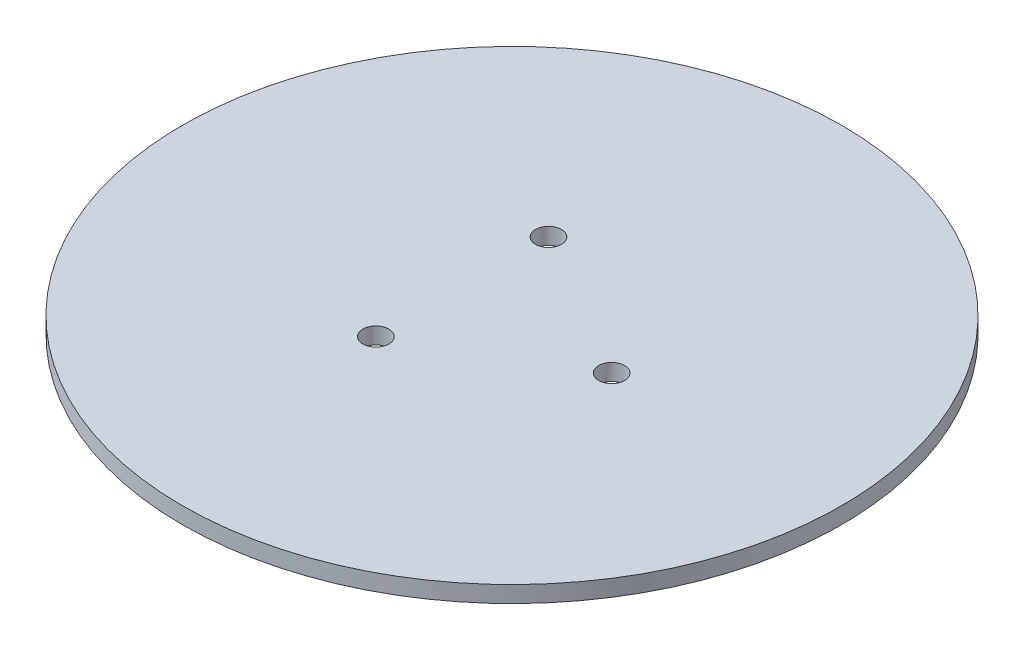
from build123d import *

# Parameters (mm, degrees)
SKETCH1_R           = 63.5
SKETCH1_R_2         = 2.5
BOSS_EXTRUDE1_DEPTH = 3.175


with BuildPart() as part:
    # Sketch1 → Boss-Extrude1 (new body)
    with BuildSketch(Plane(origin=(0, 0, 0), x_dir=(1, 0, 0), z_dir=(0, 1, 0))):
        Circle(SKETCH1_R)
        with Locations((19.2, 0)):
            Circle(SKETCH1_R_2, mode=Mode.SUBTRACT)
        with Locations((-9.6, 16.627687753)):
            Circle(SKETCH1_R_2, mode=Mode.SUBTRACT)
        with Locations((-9.6, -16.627687753)):
            Circle(SKETCH1_R_2, mode=Mode.SUBTRACT)
    extrude(amount=BOSS_EXTRUDE1_DEPTH)


solid = part.part
